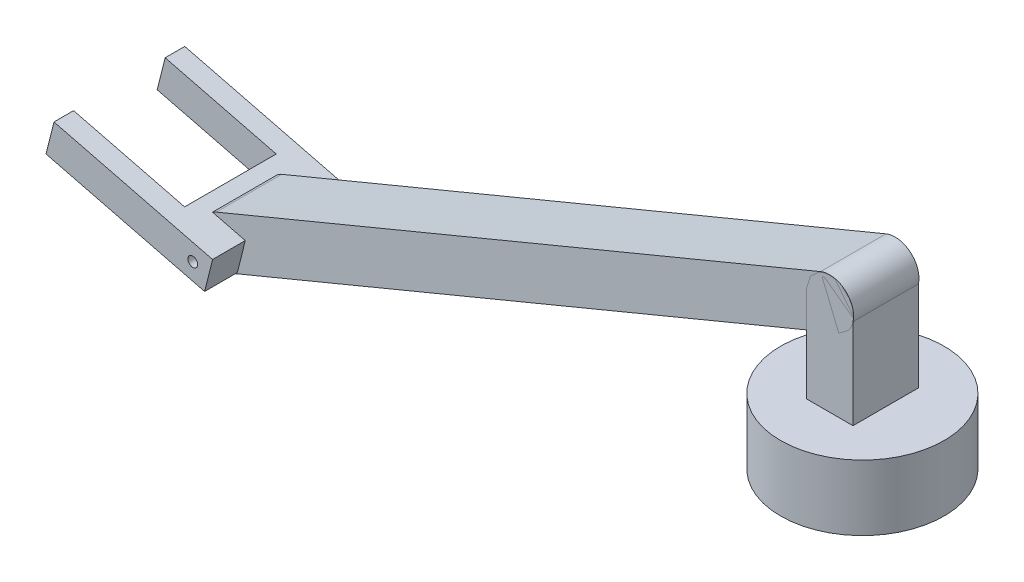
from build123d import *

# Parameters (mm, degrees)
SKETCH_2_R          = 25
EXTRUDE_1_DEPTH     = 20
EXTRUDE_2_DEPTH     = 10
EXTRUDE_3_DEPTH     = 10
SKETCH_6_R          = 1.5
EXTRUDE_4_DEPTH     = 30
SKETCH_7_W          = 35
SKETCH_7_H          = 28
SKETCH_7_W_2        = 82.955010688
SKETCH_7_H_2        = 10
CUT_EXTRUDE_1_DEPTH = 23.993907244


with BuildPart() as part:
    # 草圖2 → 填料-伸長1 (new body)
    with BuildSketch(Plane(origin=(0, 0, 0), x_dir=(1, 0, 0), z_dir=(0, 1, 0))):
        Circle(SKETCH_2_R)
    extrude(amount=EXTRUDE_1_DEPTH)

    # 草圖4 → 填料-伸長2 (add, symmetric)
    with BuildSketch(Plane.XY):
        with BuildLine():
            Line((-7.125648149, 20), (-7.125648149, 49.101375051))
            ThreePointArc((-7.125648149, 49.101375051), (0, 56.227023201), (7.125648149, 49.101375051))
            Line((7.125648149, 49.101375051), (7.125648149, 20))
            ThreePointArc((7.125648149, 20), (0, 12.874351851), (-7.125648149, 20))
        make_face()
    extrude(amount=EXTRUDE_2_DEPTH, both=True)


with BuildPart() as body_2:
    # 草圖5 → 填料-伸長3 (new body, symmetric)
    with BuildSketch(Plane.XY):
        with BuildLine():
            Line((2.797199891, 42.356410459), (-181.946306774, -34.25844936))
            ThreePointArc((-181.946306774, -34.25844936), (-191.488471258, -30.310684658), (-187.540706557, -20.768520175))
            Line((-187.540706557, -20.768520175), (-2.797199891, 55.846339644))
            ThreePointArc((-2.797199891, 55.846339644), (6.744964593, 51.898574942), (2.797199891, 42.356410459))
        make_face()
    extrude(amount=EXTRUDE_3_DEPTH, both=True)

    # 草圖6 → 填料-伸長4 (add, symmetric)
    with BuildSketch(Plane.XY):
        Polygon((-181.109627774, -33.579366748), (-178.677624685, -23.879605876), (-227.176429045, -11.71959043), (-229.608432134, -21.419351302), align=None)
        with Locations((-184.743506665, -27.513484767)):
            Circle(SKETCH_6_R, mode=Mode.SUBTRACT)
    extrude(amount=EXTRUDE_4_DEPTH, both=True)

    # 草圖7 → 除料-伸長1 (cut, through all)
    with BuildSketch(Plane(origin=(-16.201299347, -64.616994186, 0), x_dir=(0.969976087, -0.243200309, 0), z_dir=(0.243200309, 0.969976087, 0))):
        with Locations((-200.005495736, 0)):
            Rectangle(SKETCH_7_W, SKETCH_7_H)
        with Locations((-176.027990392, 25)):
            Rectangle(SKETCH_7_W_2, SKETCH_7_H_2)
        with Locations((-176.027990392, -25)):
            Rectangle(SKETCH_7_W_2, SKETCH_7_H_2)
    extrude(amount=-CUT_EXTRUDE_1_DEPTH, mode=Mode.SUBTRACT)


solid = Compound([part.part, body_2.part])
